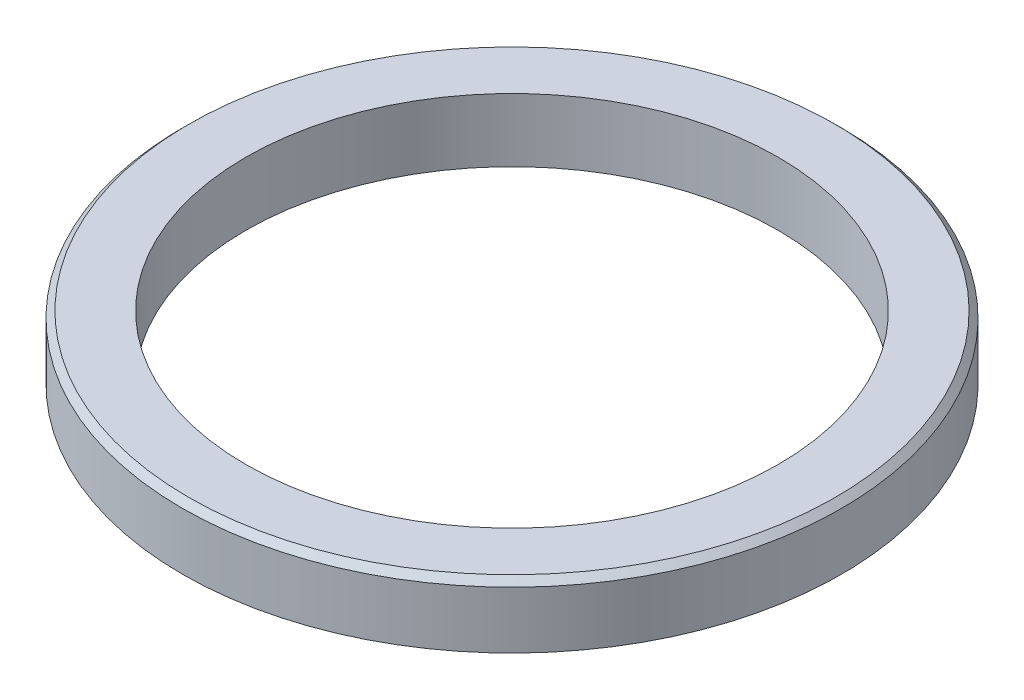
from build123d import *

# Parameters (mm, degrees)
SKETCH_1_R          = 26
EXTRUDE_1_DEPTH     = 5
CHAMFER_1_SIZE      = 0.5
SKETCH_2_R          = 21
CUT_EXTRUDE_1_DEPTH = 10


with BuildPart() as part:
    # 草图1 → 凸台-拉伸1 (new body)
    with BuildSketch(Plane(origin=(0, 0, 0), x_dir=(1, 0, 0), z_dir=(0, 1, 0))):
        Circle(SKETCH_1_R)
    extrude(amount=EXTRUDE_1_DEPTH)

    # 倒角1
    chamfer_1_edges = [part.edges().sort_by_distance(p)[0] for p in [
        (-26, 5, 0),
    ]]
    chamfer(chamfer_1_edges, length=CHAMFER_1_SIZE)

    # 草图2 → 切除-拉伸1 (cut)
    with BuildSketch(Plane(origin=(0, 5, 0), x_dir=(1, 0, 0), z_dir=(0, 1, 0))):
        Circle(SKETCH_2_R)
    extrude(amount=-CUT_EXTRUDE_1_DEPTH, mode=Mode.SUBTRACT)


solid = part.part
